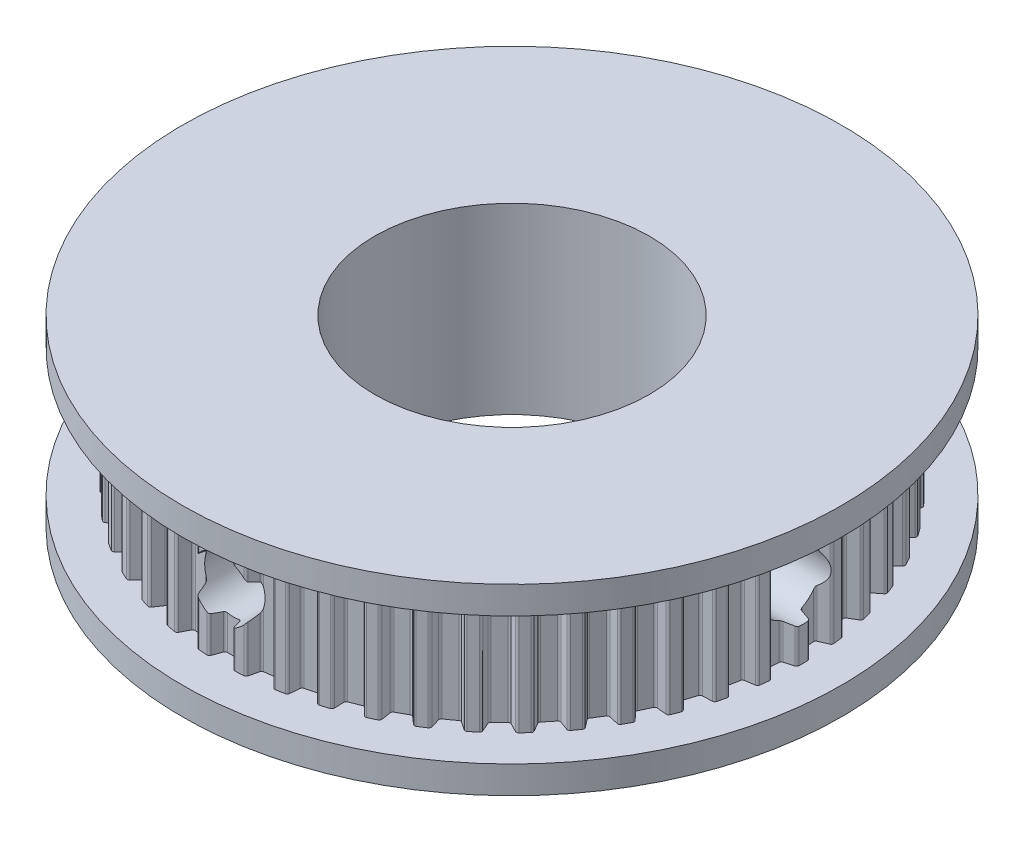
from build123d import *

# Parameters (mm, degrees)
EXTRUDE_1_DEPTH                  = 3.5
EXTRUDE_1_DEPTH_BACK             = 3.5
SKETCH_1_R                       = 15.915
CUT_EXTRUDE_1_DEPTH              = 24.570626848
FILLET_1_R                       = 0.13
PATTERN_CIRCULAR_1_COUNT         = 50
FILLET_1_OF_PATTERN_CIRCULAR_1_R = 0.13
SKETCH_3_R                       = 18
EXTRUDE_2_DEPTH                  = 1.5
EXTRUDE_START                    = 1.5
SKETCH_4_R                       = 18
EXTRUDE_3_DEPTH                  = 1.5
SKETCH_5_R                       = 7.5
CUT_EXTRUDE_2_DEPTH              = 28.349588662
SKETCH_9_W                       = 1.65
SKETCH_9_H                       = 18
PATTERN_CIRCULAR_2_COUNT         = 2
PATTERN_CIRCULAR_2_ANGLE         = 90


with BuildPart() as part:
    # 草圖1 → 填料-伸長1 (new, two sides: drawn at the far end of the back side and taken through both)
    with BuildSketch(Plane(origin=(0, 0, 0), x_dir=(1, 0, 0), z_dir=(0, 1, 0)).offset(-EXTRUDE_1_DEPTH_BACK)):
        Circle(SKETCH_1_R)
    extrude(amount=EXTRUDE_1_DEPTH + EXTRUDE_1_DEPTH_BACK)

    # 草圖2 → 除料-伸長1 (cut, through all)
    with BuildSketch(Plane.XZ.offset(3.5)):
        with BuildLine():
            ThreePointArc((0.666064277, 15.901056046), (0, 15.915), (-0.666064277, 15.901056046))
            Line((-0.666064277, 15.901056046), (-0.42, 15.225))
            Line((-0.42, 15.225), (0.42, 15.225))
            Line((0.42, 15.225), (0.666064277, 15.901056046))
        make_face()
    cut_extrude_1 = extrude(amount=-CUT_EXTRUDE_1_DEPTH, mode=Mode.SUBTRACT)

    # 圓角1
    fillet_1_edges = [part.edges().sort_by_distance(p)[0] for p in [
        (-0.666064277, -1.75, 15.901056046),
        (0.666064277, -1.75, 15.901056046),
        (0.42, 0, 15.225),
        (-0.42, 0, 15.225),
    ]]
    fillet(fillet_1_edges, radius=FILLET_1_R)

    # 環狀複製排列1: 除料-伸長1 ×50 about axis
    pattern_circular_1_axis = Axis((0, -3.5, 0), (0, 1, 0))
    for i in range(1, PATTERN_CIRCULAR_1_COUNT):
        add(cut_extrude_1.rotate(pattern_circular_1_axis, i * 360 / PATTERN_CIRCULAR_1_COUNT), mode=Mode.SUBTRACT)

    # 圓角1 of 環狀複製排列1
    fillet_1_of_pattern_circular_1_edges = [part.edges().sort_by_distance(p)[0] for p in [
        (1.33211861, -1.75, 15.859151459),
        (2.653742933, -1.75, 15.69219148),
        (2.324886656, 0, 15.052306369),
        (1.491510306, 0, 15.157586286),
        (3.309293191, -1.75, 15.56713858),
        (4.599570477, -1.75, 15.23585168),
        (4.19310846, 0, 14.642228876),
        (3.379498604, 0, 14.851128381),
        (5.234278241, -1.75, 15.029622627),
        (6.472860047, -1.75, 14.539233398),
        (5.995202439, 0, 14.001234686),
        (5.214190191, 0, 14.31045931),
        (7.076715597, -1.75, 14.255080546),
        (8.244068748, -1.75, 13.61332272),
        (7.702748494, 0, 13.139432661),
        (6.966650883, 0, 13.544105747),
        (8.80754892, -1.75, 13.255727329),
        (9.88526356, -1.75, 12.47272181),
        (9.288817604, 0, 12.070413933),
        (8.609243329, 0, 12.564153545),
        (10.399481935, -1.75, 12.047323374),
        (11.37056186, -1.75, 11.135418627),
        (10.728396511, 0, 10.811037568),
        (10.116062864, 0, 11.386057137),
        (11.827408908, -1.75, 10.648925932),
        (12.676539607, -1.75, 9.62250324),
        (11.998782197, 0, 9.381164682),
        (11.463346046, 0, 10.028395806),
        (13.068810578, -1.75, 9.082588568),
        (13.782600752, -1.75, 7.957835228),
        (13.07993992, 0, 7.803345225),
        (12.629845412, 0, 8.512580682),
        (14.104109297, -1.75, 7.373013355),
        (14.671302049, -1.75, 6.167667401),
        (13.954819176, 0, 6.102462352),
        (13.597164571, 0, 6.862517076),
        (14.916977787, -1.75, 5.547161318),
        (15.32862815, -1.75, 4.280231775),
        (14.609622598, 0, 4.305340003),
        (14.350048323, 0, 5.104227476),
        (15.494596627, -1.75, 3.633827233),
        (15.744212627, -1.75, 2.325294337),
        (15.034023544, 0, 2.440319869),
        (14.87662324, 0, 3.26544116),
        (15.827856422, -1.75, 1.663185522),
        (15.911501466, -1.75, 0.333685618),
        (15.221328959, 0, 0.536814434),
        (15.168584922, 0, 1.375156886),
        (15.911501466, -1.75, -0.333685618),
        (15.827856422, -1.75, -1.663185522),
        (15.168584922, 0, -1.375156886),
        (15.221328959, 0, -0.536814434),
        (15.744212627, -1.75, -2.325294337),
        (15.494596627, -1.75, -3.633827233),
        (14.87662324, 0, -3.26544116),
        (15.034023544, 0, -2.440319869),
        (15.32862815, -1.75, -4.280231775),
        (14.916977787, -1.75, -5.547161318),
        (14.350048323, 0, -5.104227476),
        (14.609622598, 0, -4.305340003),
        (14.671302049, -1.75, -6.167667401),
        (14.104109297, -1.75, -7.373013355),
        (13.597164571, 0, -6.862517076),
        (13.954819176, 0, -6.102462352),
        (13.782600752, -1.75, -7.957835228),
        (13.068810578, -1.75, -9.082588568),
        (12.629845412, 0, -8.512580682),
        (13.07993992, 0, -7.803345225),
        (12.676539607, -1.75, -9.62250324),
        (11.827408908, -1.75, -10.648925932),
        (11.463346046, 0, -10.028395806),
        (11.998782197, 0, -9.381164682),
        (11.37056186, -1.75, -11.135418627),
        (10.399481935, -1.75, -12.047323374),
        (10.116062864, 0, -11.386057137),
        (10.728396511, 0, -10.811037568),
        (9.88526356, -1.75, -12.47272181),
        (8.80754892, -1.75, -13.255727329),
        (8.609243329, 0, -12.564153545),
        (9.288817604, 0, -12.070413933),
        (8.244068748, -1.75, -13.61332272),
        (7.076715597, -1.75, -14.255080546),
        (6.966650883, 0, -13.544105747),
        (7.702748494, 0, -13.139432661),
        (6.472860047, -1.75, -14.539233398),
        (5.234278241, -1.75, -15.029622627),
        (5.214190191, 0, -14.31045931),
        (5.995202439, 0, -14.001234686),
        (4.599570477, -1.75, -15.23585168),
        (3.309293191, -1.75, -15.56713858),
        (3.379498604, 0, -14.851128381),
        (4.19310846, 0, -14.642228876),
        (2.653742933, -1.75, -15.69219148),
        (1.33211861, -1.75, -15.859151459),
        (1.491510306, 0, -15.157586286),
        (2.324886656, 0, -15.052306369),
        (0.666064277, -1.75, -15.901056046),
        (-0.666064277, -1.75, -15.901056046),
        (-0.42, 0, -15.225),
        (0.42, 0, -15.225),
        (-1.33211861, -1.75, -15.859151459),
        (-2.653742933, -1.75, -15.69219148),
        (-2.324886656, 0, -15.052306369),
        (-1.491510306, 0, -15.157586286),
        (-3.309293191, -1.75, -15.56713858),
        (-4.599570477, -1.75, -15.23585168),
        (-4.19310846, 0, -14.642228876),
        (-3.379498604, 0, -14.851128381),
        (-5.234278241, -1.75, -15.029622627),
        (-6.472860047, -1.75, -14.539233398),
        (-5.995202439, 0, -14.001234686),
        (-5.214190191, 0, -14.31045931),
        (-7.076715597, -1.75, -14.255080546),
        (-8.244068748, -1.75, -13.61332272),
        (-7.702748494, 0, -13.139432661),
        (-6.966650883, 0, -13.544105747),
        (-8.80754892, -1.75, -13.255727329),
        (-9.88526356, -1.75, -12.47272181),
        (-9.288817604, 0, -12.070413933),
        (-8.609243329, 0, -12.564153545),
        (-10.399481935, -1.75, -12.047323374),
        (-11.37056186, -1.75, -11.135418627),
        (-10.728396511, 0, -10.811037568),
        (-10.116062864, 0, -11.386057137),
        (-11.827408908, -1.75, -10.648925932),
        (-12.676539607, -1.75, -9.62250324),
        (-11.998782197, 0, -9.381164682),
        (-11.463346046, 0, -10.028395806),
        (-13.068810578, -1.75, -9.082588568),
        (-13.782600752, -1.75, -7.957835228),
        (-13.07993992, 0, -7.803345225),
        (-12.629845412, 0, -8.512580682),
        (-14.104109297, -1.75, -7.373013355),
        (-14.671302049, -1.75, -6.167667401),
        (-13.954819176, 0, -6.102462352),
        (-13.597164571, 0, -6.862517076),
        (-14.916977787, -1.75, -5.547161318),
        (-15.32862815, -1.75, -4.280231775),
        (-14.609622598, 0, -4.305340003),
        (-14.350048323, 0, -5.104227476),
        (-15.494596627, -1.75, -3.633827233),
        (-15.744212627, -1.75, -2.325294337),
        (-15.034023544, 0, -2.440319869),
        (-14.87662324, 0, -3.26544116),
        (-15.827856422, -1.75, -1.663185522),
        (-15.911501466, -1.75, -0.333685618),
        (-15.221328959, 0, -0.536814434),
        (-15.168584922, 0, -1.375156886),
        (-15.911501466, -1.75, 0.333685618),
        (-15.827856422, -1.75, 1.663185522),
        (-15.168584922, 0, 1.375156886),
        (-15.221328959, 0, 0.536814434),
        (-15.744212627, -1.75, 2.325294337),
        (-15.494596627, -1.75, 3.633827233),
        (-14.87662324, 0, 3.26544116),
        (-15.034023544, 0, 2.440319869),
        (-15.32862815, -1.75, 4.280231775),
        (-14.916977787, -1.75, 5.547161318),
        (-14.350048323, 0, 5.104227476),
        (-14.609622598, 0, 4.305340003),
        (-14.671302049, -1.75, 6.167667401),
        (-14.104109297, -1.75, 7.373013355),
        (-13.597164571, 0, 6.862517076),
        (-13.954819176, 0, 6.102462352),
        (-13.782600752, -1.75, 7.957835228),
        (-13.068810578, -1.75, 9.082588568),
        (-12.629845412, 0, 8.512580682),
        (-13.07993992, 0, 7.803345225),
        (-12.676539607, -1.75, 9.62250324),
        (-11.827408908, -1.75, 10.648925932),
        (-11.463346046, 0, 10.028395806),
        (-11.998782197, 0, 9.381164682),
        (-11.37056186, -1.75, 11.135418627),
        (-10.399481935, -1.75, 12.047323374),
        (-10.116062864, 0, 11.386057137),
        (-10.728396511, 0, 10.811037568),
        (-9.88526356, -1.75, 12.47272181),
        (-8.80754892, -1.75, 13.255727329),
        (-8.609243329, 0, 12.564153545),
        (-9.288817604, 0, 12.070413933),
        (-8.244068748, -1.75, 13.61332272),
        (-7.076715597, -1.75, 14.255080546),
        (-6.966650883, 0, 13.544105747),
        (-7.702748494, 0, 13.139432661),
        (-6.472860047, -1.75, 14.539233398),
        (-5.234278241, -1.75, 15.029622627),
        (-5.214190191, 0, 14.31045931),
        (-5.995202439, 0, 14.001234686),
        (-4.599570477, -1.75, 15.23585168),
        (-3.309293191, -1.75, 15.56713858),
        (-3.379498604, 0, 14.851128381),
        (-4.19310846, 0, 14.642228876),
        (-2.653742933, -1.75, 15.69219148),
        (-1.33211861, -1.75, 15.859151459),
        (-1.491510306, 0, 15.157586286),
        (-2.324886656, 0, 15.052306369),
    ]]
    fillet(fillet_1_of_pattern_circular_1_edges, radius=FILLET_1_OF_PATTERN_CIRCULAR_1_R)

    # 草圖3 → 填料-伸長2 (add)
    with BuildSketch(Plane(origin=(0, 3.5, 0), x_dir=(1, 0, 0), z_dir=(0, 1, 0))):
        Circle(SKETCH_3_R)
    extrude(amount=EXTRUDE_2_DEPTH)

    # 草圖4 → 填料-伸長3 (add)
    with BuildSketch(Plane.XZ.offset(3.5).offset(EXTRUDE_START)):
        Circle(SKETCH_4_R)
    extrude(amount=-EXTRUDE_3_DEPTH)

    # 草圖5 → 除料-伸長2 (cut, through all)
    with BuildSketch(Plane.XZ.offset(5)):
        Circle(SKETCH_5_R)
    extrude(amount=-CUT_EXTRUDE_2_DEPTH, mode=Mode.SUBTRACT)

    # 草圖9 → M4x0.7 螺紋孔1 (revolve, cut)
    with BuildSketch(Plane.YZ):
        with Locations((0.825, 9)):
            Rectangle(SKETCH_9_W, SKETCH_9_H)
    m4x0_7_1 = revolve(axis=Axis((0, 0, -6.35), (0, 0, 1)), mode=Mode.SUBTRACT)

    # 環狀複製排列2: M4x0.7 螺紋孔1 ×2 about axis
    pattern_circular_2_axis = Axis((0, 5, 0), (0, 1, 0))
    for i in range(1, PATTERN_CIRCULAR_2_COUNT):
        add(m4x0_7_1.rotate(pattern_circular_2_axis, i * PATTERN_CIRCULAR_2_ANGLE / (PATTERN_CIRCULAR_2_COUNT - 1)), mode=Mode.SUBTRACT)


solid = part.part
